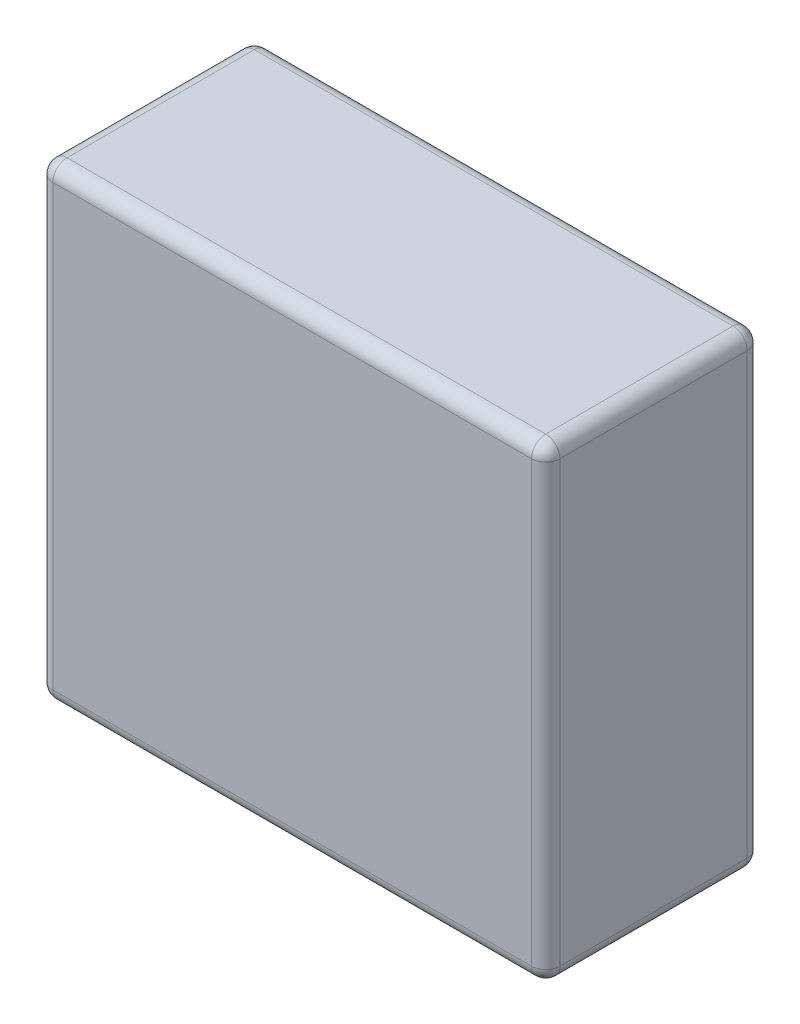
from build123d import *

# Parameters (mm, degrees)
SKETCH2_W           = 77
SKETCH2_H           = 167
BOSS_EXTRUDE1_DEPTH = 181
FILLET1_R           = 5.08


with BuildPart() as part:
    # Sketch2 → Boss-Extrude1 (new body)
    with BuildSketch(Plane(origin=(0, 0, 0), x_dir=(0, 0, -1), z_dir=(1, 0, 0))):
        with Locations((38.5, 83.5)):
            Rectangle(SKETCH2_W, SKETCH2_H)
    extrude(amount=BOSS_EXTRUDE1_DEPTH)

    # Fillet1
    fillet1_edges = [part.edges().sort_by_distance(p)[0] for p in [
        (181, 83.5, -77),
        (181, 167, -38.5),
        (181, 83.5, 0),
        (0, 167, -38.5),
        (0, 83.5, -77),
        (0, 0, -38.5),
        (0, 83.5, 0),
        (181, 0, -38.5),
        (90.5, 167, 0),
        (90.5, 167, -77),
        (90.5, 0, -77),
        (90.5, 0, 0),
    ]]
    fillet(fillet1_edges, radius=FILLET1_R)


solid = part.part
